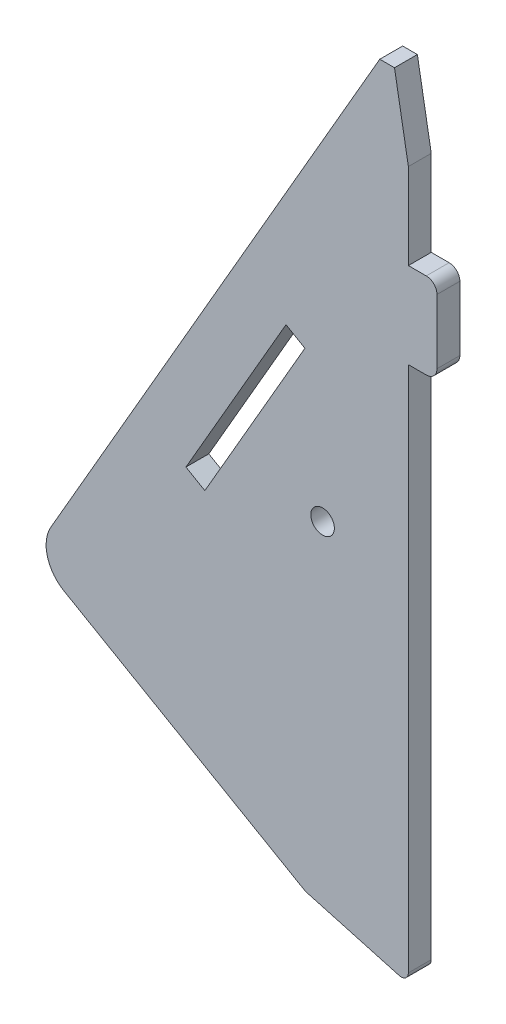
from build123d import *

# Parameters (mm, degrees)
SKETCH1_R           = 1.65
BOSS_EXTRUDE1_DEPTH = 3.2
SKETCH2_W           = 4
SKETCH2_H           = 12
BOSS_EXTRUDE2_DEPTH = 3.2
FILLET1_R           = 1.5


with BuildPart() as part:
    # Sketch1 → Boss-Extrude1 (new body)
    with BuildSketch(Plane.XY):
        with BuildLine():
            Line((1.830127019, -31.504464167), (35.605117766, -51.004464167))
            Line((35.605117766, -51.004464167), (48.732545217, -54.648197122))
            ThreePointArc((48.732545217, -54.648197122), (49.6052046, -54.480696676), (50, -53.68462671))
            Line((50, -53.68462671), (50, 44))
            Line((50, 44), (48.060403212, 55))
            Line((48.060403212, 55), (46, 55))
            Line((46, 55), (0, -24.674337148))
            ThreePointArc((0, -24.674337148), (-0.499502113, -28.468432374), (1.830127019, -31.504464167))
        make_face()
        with Locations((38, -5)):
            Circle(SKETCH1_R, mode=Mode.SUBTRACT)
        Polygon((18.88414205, -7.96604366), (32.88414205, 16.282667646), (35.534179786, 14.752667646), (21.534179786, -9.49604366), align=None, mode=Mode.SUBTRACT)
    extrude(amount=BOSS_EXTRUDE1_DEPTH)

    # Sketch2 → Boss-Extrude2 (add)
    with BuildSketch(Plane.XY.offset(3.2)):
        with Locations((52, 26)):
            Rectangle(SKETCH2_W, SKETCH2_H)
    extrude(amount=-BOSS_EXTRUDE2_DEPTH)

    # Fillet1
    fillet1_edges = [part.edges().sort_by_distance(p)[0] for p in [
        (54, 32, 1.6),
        (54, 20, 1.6),
    ]]
    fillet(fillet1_edges, radius=FILLET1_R)


solid = part.part
